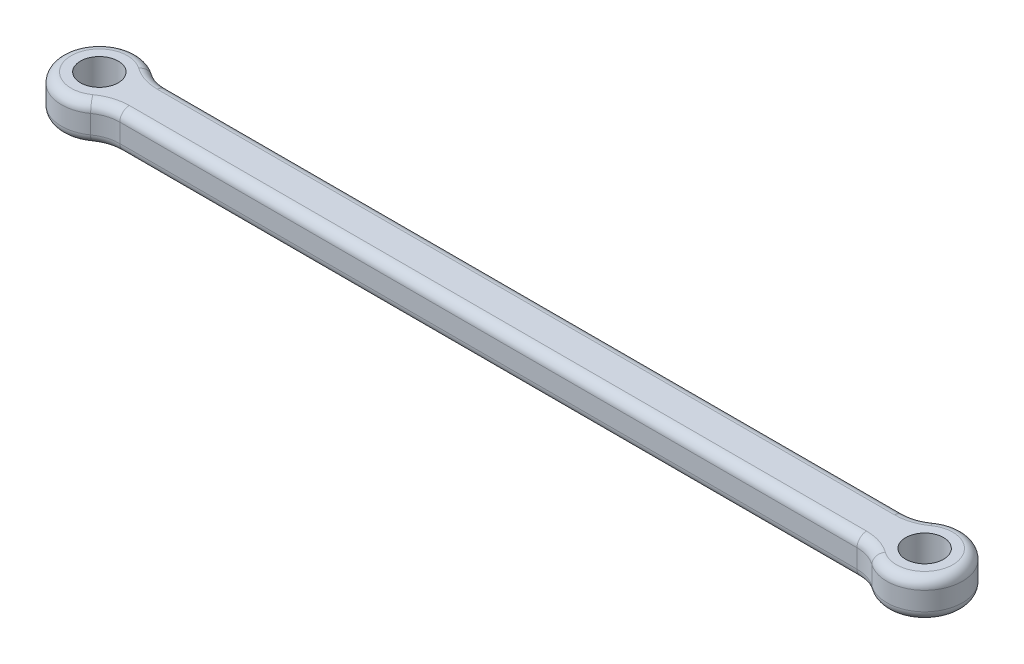
from build123d import *

# Parameters (mm, degrees)
SKETCH1_R           = 5
BOSS_EXTRUDE1_DEPTH = 10
FILLET1_R           = 2.54
SCALE1_SCALE        = 0.66


with BuildPart() as part:
    # Sketch1 → Boss-Extrude1 (new body)
    with BuildSketch(Plane(origin=(0, 0, 0), x_dir=(1, 0, 0), z_dir=(0, 1, 0))):
        with BuildLine():
            Line((-42.950776184, -6.25), (152.170776184, -6.25))
            ThreePointArc((152.170776184, -6.25), (155.232638362, -6.730283618), (158.000388092, -8.125))
            ThreePointArc((158.000388092, -8.125), (173.83, 0), (158.000388092, 8.125))
            ThreePointArc((158.000388092, 8.125), (155.232638362, 6.730283618), (152.170776184, 6.25))
            Line((152.170776184, 6.25), (-42.950776184, 6.25))
            ThreePointArc((-42.950776184, 6.25), (-46.012638362, 6.730283618), (-48.780388092, 8.125))
            ThreePointArc((-48.780388092, 8.125), (-64.61, 0), (-48.780388092, -8.125))
            ThreePointArc((-48.780388092, -8.125), (-46.012638362, -6.730283618), (-42.950776184, -6.25))
        make_face()
        with Locations((-54.61, 0)):
            Circle(SKETCH1_R, mode=Mode.SUBTRACT)
        with Locations((163.83, 0)):
            Circle(SKETCH1_R, mode=Mode.SUBTRACT)
    extrude(amount=BOSS_EXTRUDE1_DEPTH)

    # Fillet1
    fillet1_edges = [part.edges().sort_by_distance(p)[0] for p in [
        (-46.012638362, 10, 6.730283618),
        (-64.61, 0, 0),
        (-46.012638362, 0, -6.730283618),
        (54.61, 10, 6.25),
        (155.232638362, 10, 6.730283618),
        (173.83, 10, 0),
        (155.232638362, 10, -6.730283618),
        (54.61, 10, -6.25),
        (-46.012638362, 10, -6.730283618),
        (-64.61, 10, 0),
        (54.61, 0, -6.25),
        (155.232638362, 0, -6.730283618),
        (173.83, 0, 0),
        (155.232638362, 0, 6.730283618),
        (54.61, 0, 6.25),
        (-46.012638362, 0, 6.730283618),
    ]]
    fillet(fillet1_edges, radius=FILLET1_R)


with BuildPart() as part_1:
    # Scale1: scaled about (54.61, 5, 0)
    add(part.part.scale(SCALE1_SCALE).moved(Location((18.5674, 1.7, 0))))


solid = part_1.part
